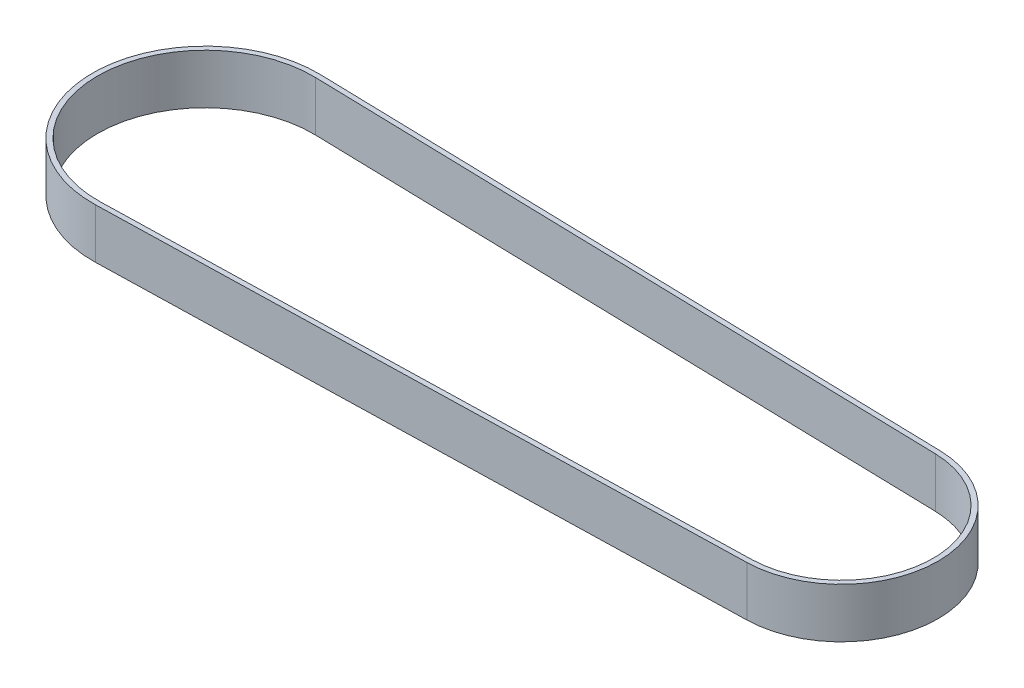
from build123d import *

# Parameters (mm, degrees)
BOSS_EXTRUDE1_DEPTH = 10


with BuildPart() as part:
    # Sketch1 → Boss-Extrude1 (new body)
    with BuildSketch(Plane(origin=(0, 0, 0), x_dir=(1, 0, 0), z_dir=(0, 1, 0))):
        with BuildLine():
            Line((0.566637938, 22.592895375), (128.116406017, 19.39390134))
            ThreePointArc((128.116406017, 19.39390134), (147.03, 0), (128.116406017, -19.39390134))
            Line((128.116406017, -19.39390134), (0.566637938, -22.592895375))
            ThreePointArc((0.566637938, -22.592895375), (-22.6, 0), (0.566637938, 22.592895375))
        make_face()
        with BuildLine():
            Line((0.541565463, 21.593209739), (128.091333542, 18.394215704))
            ThreePointArc((128.091333542, 18.394215704), (146.03, 0), (128.091333542, -18.394215704))
            Line((128.091333542, -18.394215704), (0.541565463, -21.593209739))
            ThreePointArc((0.541565463, -21.593209739), (-21.6, 0), (0.541565463, 21.593209739))
        make_face(mode=Mode.SUBTRACT)
    extrude(amount=BOSS_EXTRUDE1_DEPTH)


solid = part.part
